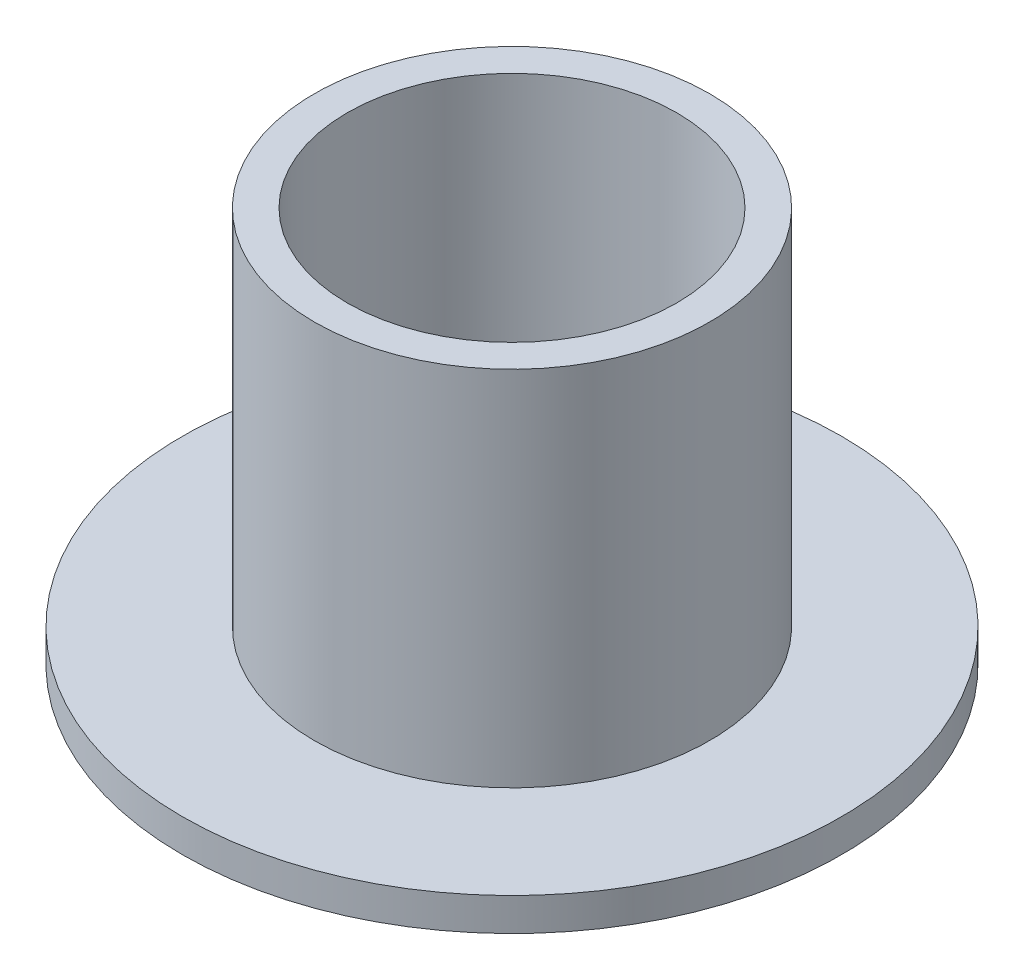
from build123d import *

# Parameters (mm, degrees)
SKIZZE1_R                       = 3
SKIZZE1_R_2                     = 2.5
AUFSATZ_LINEAR_AUSTRAGEN1_DEPTH = 6
SKIZZE2_R                       = 5
SKIZZE2_R_2                     = 3
AUFSATZ_LINEAR_AUSTRAGEN2_DEPTH = 0.5


with BuildPart() as part:
    # Skizze1 → Aufsatz-Linear austragen1 (new body)
    with BuildSketch(Plane(origin=(0, 0, 0), x_dir=(1, 0, 0), z_dir=(0, 1, 0))):
        Circle(SKIZZE1_R)
        Circle(SKIZZE1_R_2, mode=Mode.SUBTRACT)
    extrude(amount=AUFSATZ_LINEAR_AUSTRAGEN1_DEPTH)

    # Skizze2 → Aufsatz-Linear austragen2 (add)
    with BuildSketch(Plane(origin=(0, 0, 0), x_dir=(1, 0, 0), z_dir=(0, 1, 0))):
        Circle(SKIZZE2_R)
        Circle(SKIZZE2_R_2, mode=Mode.SUBTRACT)
    extrude(amount=AUFSATZ_LINEAR_AUSTRAGEN2_DEPTH)


solid = part.part
